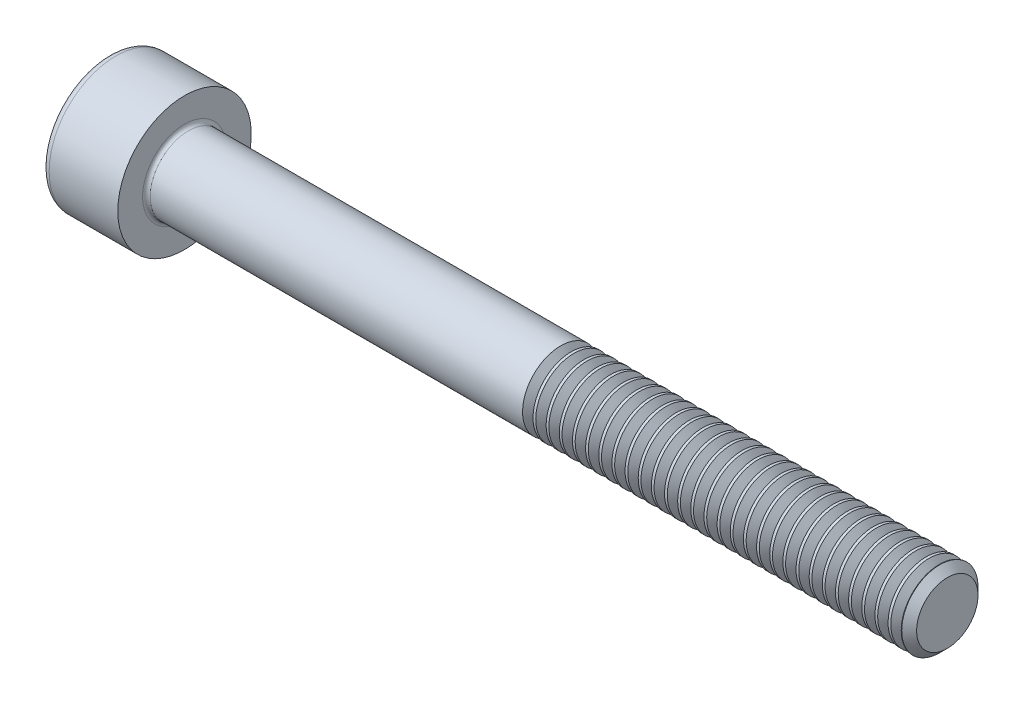
from build123d import *

# Parameters (mm, degrees)
FILLET1_R       = 0.2
FILLET2_R       = 0.4
HEX_2_DEPTH     = 2
THDSCHPAT_COUNT = 29
THDSCHPAT_PITCH = 0.689655172


with BuildPart() as part:
    # BodySke → Base-Revolve (revolve)
    with BuildSketch(Plane.XY, mode=Mode.PRIVATE) as base_revolve_sk:
        Polygon((0, 0), (0, 3.5), (4, 3.5), (4, 2), (43.61, 2), (44, 1.61), (44, 0), align=None)
    revolve(base_revolve_sk.sketch.rotate(Axis((-31.75, 0, 0), (1, 0, 0)), 90), axis=Axis((-31.75, 0, 0), (1, 0, 0)))  # turned: the seam where the file's is

    # Fillet1
    fillet1_edges = [part.edges().sort_by_distance(p)[0] for p in [
        (4, 0, -2),
    ]]
    fillet(fillet1_edges, radius=FILLET1_R)

    # Fillet2
    fillet2_edges = [part.edges().sort_by_distance(p)[0] for p in [
        (0, 0, -3.5),
    ]]
    fillet(fillet2_edges, radius=FILLET2_R)

    # Sketch2 → Hex-PreBroach (revolve, cut)
    with BuildSketch(Plane.XY, mode=Mode.PRIVATE) as hex_prebroach_sk:
        Polygon((0, 1.51), (2, 1.51), (2.871798906, 0), (0, 0), align=None)
    revolve(hex_prebroach_sk.sketch.rotate(Axis((0, 0, 0), (1, 0, 0)), 90), axis=Axis((0, 0, 0), (1, 0, 0)), mode=Mode.SUBTRACT)  # turned: the seam where the file's is

    # Sketch3 → Hex 2 (cut)
    with BuildSketch(Plane(origin=(0, 0, 0), x_dir=(0, 0.5, 0.866025404), z_dir=(-1, 0, 0))):
        Polygon((0.871798906, 1.51), (-0.871798906, 1.51), (-1.743597813, 0), (-0.871798906, -1.51), (0.871798906, -1.51), (1.743597813, 0), align=None)
    extrude(amount=-HEX_2_DEPTH, mode=Mode.SUBTRACT)

    # ThdSchSke → ThreadSchematic (revolve, cut)
    with BuildSketch(Plane.XY, mode=Mode.PRIVATE) as threadschematic_sk:
        Polygon((24, -1.61), (23.72691906, -2), (23.72691906, -2.5), (24.27308094, -2.5), (24.27308094, -2), align=None)
    threadschematic = revolve(threadschematic_sk.sketch.rotate(Axis((-3.175, 0, 0), (1, 0, 0)), 270), axis=Axis((-3.175, 0, 0), (1, 0, 0)), mode=Mode.SUBTRACT)  # turned: the seam where the file's is

    # ThdSchPat: ThreadSchematic ×29
    with Locations(*[(i * THDSCHPAT_PITCH, 0, 0) for i in range(1, THDSCHPAT_COUNT)]):
        add(threadschematic, mode=Mode.SUBTRACT)


solid = part.part
